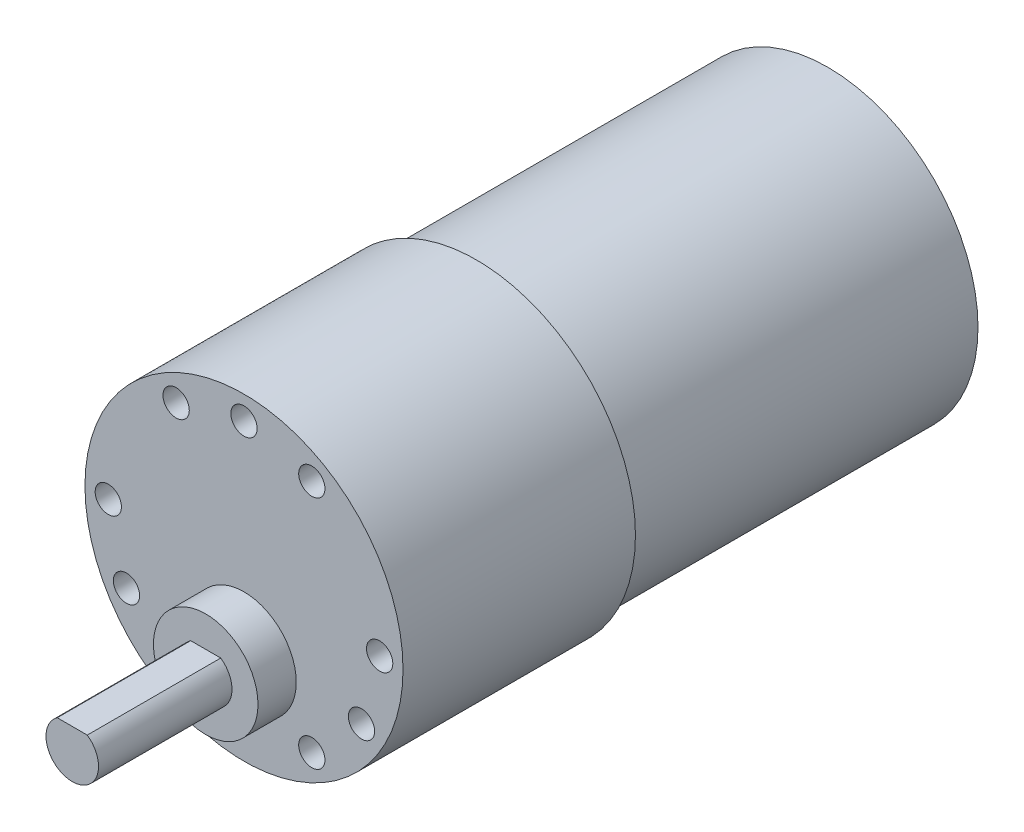
from build123d import *

# Parameters (mm, degrees)
SKETCH1_R           = 18.161
BOSS_EXTRUDE1_DEPTH = 26.543
SKETCH5_R           = 5.969
BOSS_EXTRUDE5_DEPTH = 4.3688
BOSS_EXTRUDE6_DEPTH = 15.24
CIRPATTERN2_COUNT   = 12
SKETCH2_R           = 17.145
BOSS_EXTRUDE2_DEPTH = 40.132
SKETCH3_R           = 3.048
BOSS_EXTRUDE3_DEPTH = 3.81
SKETCH13_R          = 16.637
CUT_EXTRUDE1_DEPTH  = 1.016
SKETCH15_W          = 2.54
SKETCH15_H          = 5.08
SKETCH15_R          = 0.4445
BOSS_EXTRUDE7_DEPTH = 0.254
SKETCH16_W          = 2.54
SKETCH16_H          = 5.08
SKETCH16_R          = 0.678606607
BOSS_EXTRUDE8_DEPTH = 0.254


with BuildPart() as part:
    # Sketch1 → Boss-Extrude1 (new body)
    with BuildSketch(Plane.XY):
        Circle(SKETCH1_R)
    extrude(amount=BOSS_EXTRUDE1_DEPTH)

    # Sketch5 → Boss-Extrude5 (add)
    with BuildSketch(Plane.XY.offset(26.543)):
        with Locations((0, -7.366)):
            Circle(SKETCH5_R)
    extrude(amount=BOSS_EXTRUDE5_DEPTH)

    # Sketch6 → Boss-Extrude6 (add)
    with BuildSketch(Plane.XY.offset(30.9118)):
        with BuildLine():
            Line((-1.715657017, -4.905), (1.715657017, -4.905))
            ThreePointArc((1.715657017, -4.905), (0, -10.366), (-1.715657017, -4.905))
        make_face()
    extrude(amount=BOSS_EXTRUDE6_DEPTH)

    # Sketch12 → Ø3.0mm Dowel Hole1 (revolve, cut)
    with BuildSketch(Plane(origin=(0, 15.494, 26.543), x_dir=(0, -1, 0), z_dir=(1, 0, 0))):
        Polygon((0, 0), (0, 11.061290929), (1.5, 10.16), (1.5, 0), align=None)
    f_3_0mm_dowel_hole1 = revolve(axis=Axis((0, 15.494, 32.893), (0, 0, -1)), mode=Mode.SUBTRACT)

    # CirPattern2: Ø3.0mm Dowel Hole1 ×12 about axis, 3 skipped
    cirpattern2_axis = Axis((0, 0, 0), (0, 0, -1))
    add([f_3_0mm_dowel_hole1.rotate(cirpattern2_axis, i * 360 / CIRPATTERN2_COUNT) for i in range(1, CIRPATTERN2_COUNT) if i not in (2, 6, 10)], mode=Mode.SUBTRACT)

    # Sketch2 → Boss-Extrude2 (add)
    with BuildSketch(Plane(origin=(0, 0, 0), x_dir=(-1, 0, 0), z_dir=(0, 0, -1))):
        Circle(SKETCH2_R)
    extrude(amount=BOSS_EXTRUDE2_DEPTH)

    # Sketch3 → Boss-Extrude3 (add)
    with BuildSketch(Plane(origin=(0, 0, -40.132), x_dir=(-1, 0, 0), z_dir=(0, 0, -1))):
        Circle(SKETCH3_R)
    extrude(amount=BOSS_EXTRUDE3_DEPTH)

    # Sketch13 → Cut-Extrude1 (cut)
    with BuildSketch(Plane(origin=(0, 0, -40.132), x_dir=(-1, 0, 0), z_dir=(0, 0, -1))):
        Circle(SKETCH13_R)
    extrude(amount=-CUT_EXTRUDE1_DEPTH, mode=Mode.SUBTRACT)

    # Sketch15 → Boss-Extrude7 (add, symmetric)
    with BuildSketch(Plane(origin=(0, 0, 0), x_dir=(0.64278761, -0.766044443, 0), z_dir=(0.766044443, 0.64278761, 0))):
        with Locations((10.16, 41.656)):
            Rectangle(SKETCH15_W, SKETCH15_H)
        with Locations((10.16, 42.926)):
            Circle(SKETCH15_R, mode=Mode.SUBTRACT)
    extrude(amount=BOSS_EXTRUDE7_DEPTH, both=True)

    # Sketch16 → Boss-Extrude8 (add, symmetric)
    with BuildSketch(Plane(origin=(0, 0, 0), x_dir=(-0.258819045, -0.965925826, 0), z_dir=(0.965925826, -0.258819045, 0))):
        with Locations((11.43, 41.656)):
            Rectangle(SKETCH16_W, SKETCH16_H)
        with Locations((11.43, 42.926)):
            Circle(SKETCH16_R, mode=Mode.SUBTRACT)
    extrude(amount=BOSS_EXTRUDE8_DEPTH, both=True)


solid = part.part
